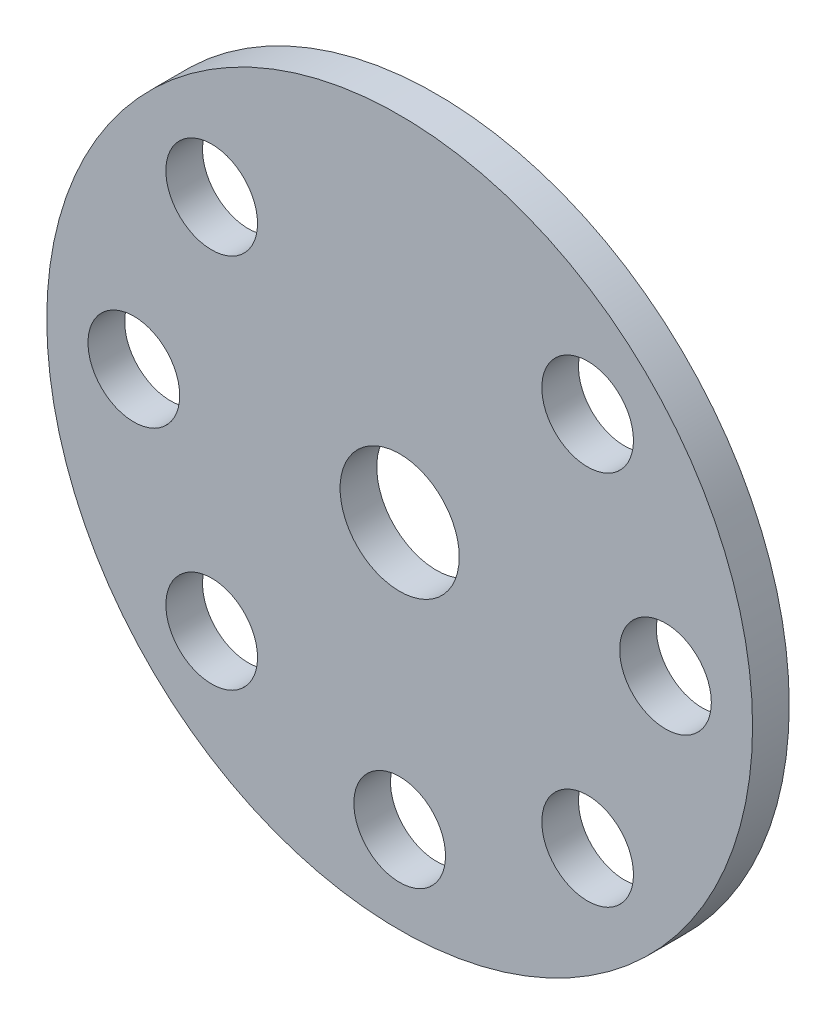
from build123d import *

# Parameters (mm, degrees)
SKETCH_1_R          = 19.25
EXTRUDE_1_DEPTH     = 2
SKETCH_4_R          = 2.5
SKETCH_4_R_2        = 3.25
CUT_EXTRUDE_2_DEPTH = 3


with BuildPart() as part:
    # Эскиз1 → Вытянуть1 (new body)
    with BuildSketch(Plane.XY):
        Circle(SKETCH_1_R)
    extrude(amount=EXTRUDE_1_DEPTH)

    # Эскиз4 → Вытянуть2 (cut, through all)
    with BuildSketch(Plane.XY.offset(2)):
        with Locations((-10.253048327, 10.253048327)):
            Circle(SKETCH_4_R)
        with Locations((-14.5, 0)):
            Circle(SKETCH_4_R)
        with Locations((-10.253048327, -10.253048327)):
            Circle(SKETCH_4_R)
        with Locations((0, -14.5)):
            Circle(SKETCH_4_R)
        with Locations((10.253048327, -10.253048327)):
            Circle(SKETCH_4_R)
        with Locations((14.5, 0)):
            Circle(SKETCH_4_R)
        with Locations((10.253048327, 10.253048327)):
            Circle(SKETCH_4_R)
        Circle(SKETCH_4_R_2)
    extrude(amount=-CUT_EXTRUDE_2_DEPTH, mode=Mode.SUBTRACT)


solid = part.part
